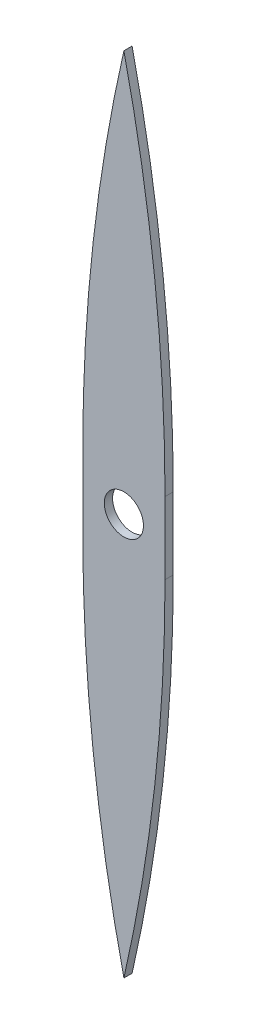
from build123d import *

# Parameters (mm, degrees)
BOSS_EXTRUDE1_DEPTH     = 2
SKETCH9_R               = 4.76
CUT_EXTRUDE1_DEPTH      = 15
CUT_EXTRUDE1_DEPTH_BACK = 16


with BuildPart() as part:
    # Sketch2 → Boss-Extrude1 (new body)
    with BuildSketch(Plane.XY):
        with BuildLine():
            Line((-10, -3.679637035), (-10, 13.820362965))
            ThreePointArc((-10, 13.820362965), (-7.492138287, 58.541722515), (0, 102.702307138))
            ThreePointArc((0, 102.702307138), (7.492138287, 58.541722515), (10, 13.820362965))
            Line((10, 13.820362965), (10, -3.679637035))
            ThreePointArc((10, -3.679637035), (7.492466261, -48.398081393), (0.001303671, -92.555860711))
            Line((0.001303671, -92.555860711), (-0.001303671, -92.555860711))
            ThreePointArc((-0.001303671, -92.555860711), (-7.492466261, -48.398081393), (-10, -3.679637035))
        make_face()
    extrude(amount=BOSS_EXTRUDE1_DEPTH)

    # Sketch9 → Cut-Extrude1 (cut, two sides)
    with BuildSketch(Plane(origin=(0, 0, 0), x_dir=(-1, 0, 0), z_dir=(0, 0, -1))) as cut_extrude1_sk:
        with Locations((-0.000651835, 5.073223214)):
            Circle(SKETCH9_R)
    extrude(amount=CUT_EXTRUDE1_DEPTH, mode=Mode.SUBTRACT)
    extrude(cut_extrude1_sk.sketch, amount=-CUT_EXTRUDE1_DEPTH_BACK, mode=Mode.SUBTRACT)


solid = part.part
